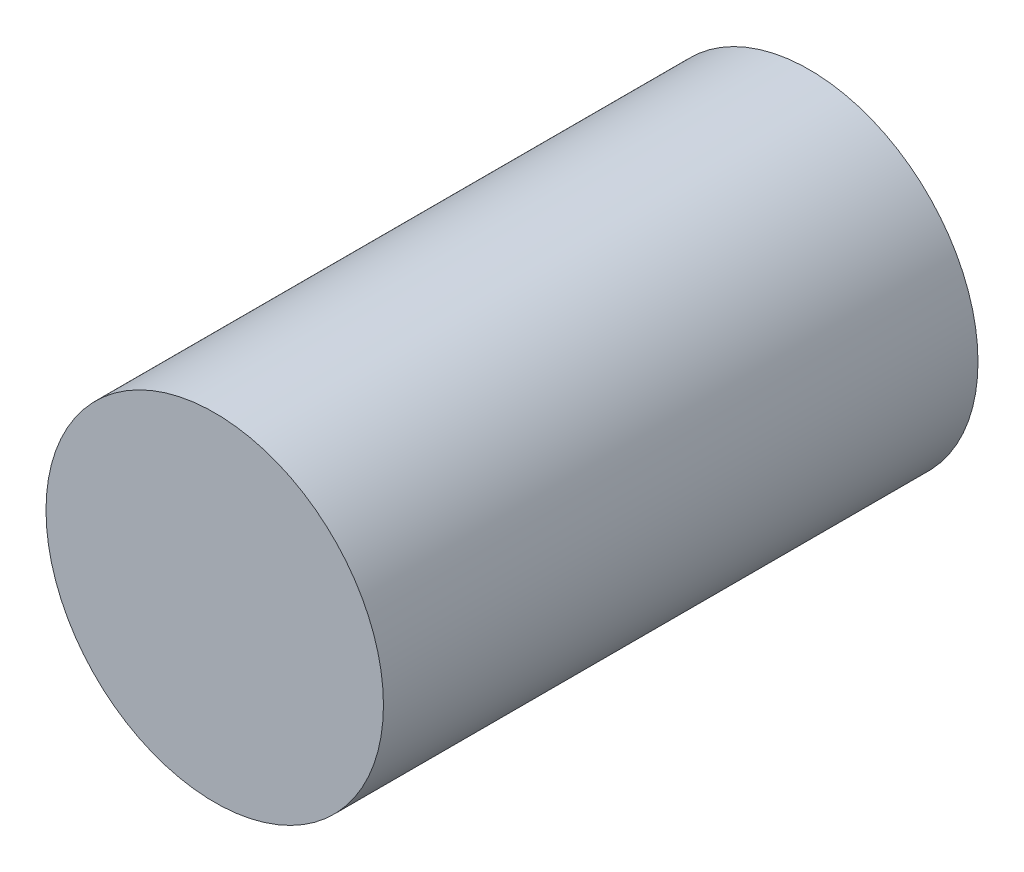
from build123d import *

# Parameters (mm, degrees)
CROQUIS1_R              = 21
SALIENTE_EXTRUIR1_DEPTH = 74


with BuildPart() as part:
    # Croquis1 → Saliente-Extruir1 (new body)
    with BuildSketch(Plane.XY):
        Circle(CROQUIS1_R)
    extrude(amount=SALIENTE_EXTRUIR1_DEPTH)


solid = part.part
